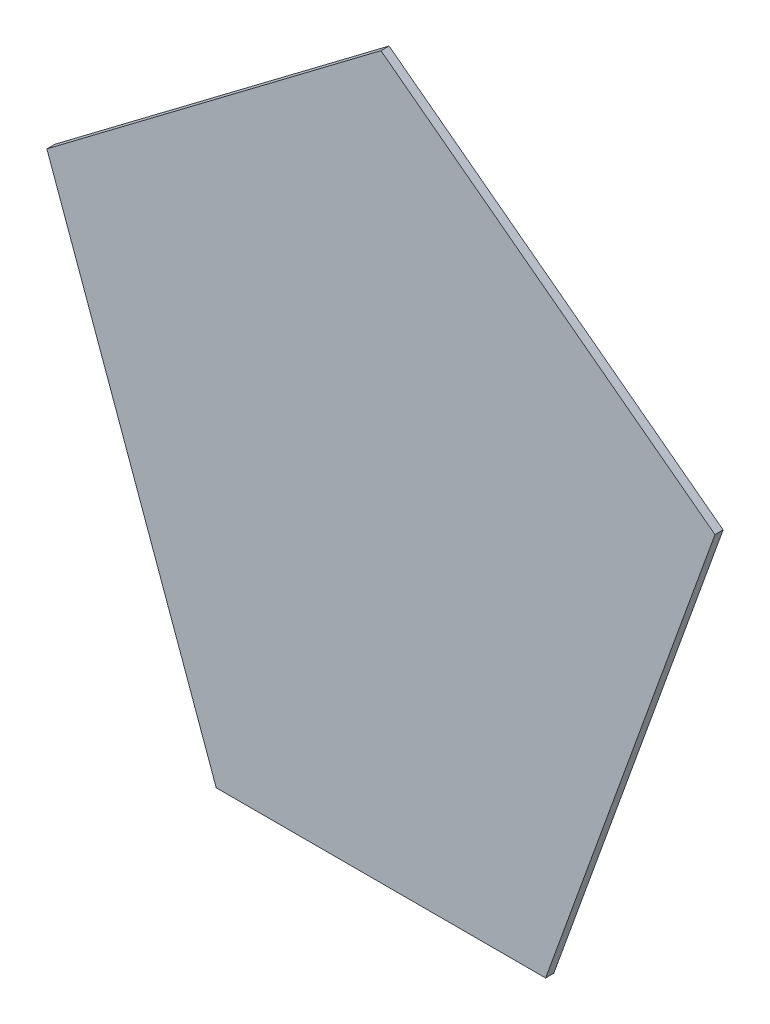
from build123d import *

# Parameters (mm, degrees)
BOSS_EXTRU_1_DEPTH = 3.5


with BuildPart() as part:
    # Esquisse1 → Boss.-Extru.1 (new body)
    with BuildSketch(Plane.XY):
        Polygon((-7.772495449, -270.02659005), (-151.459873294, -378.442167565), (-78.608554807, -580.02659005), (63.06356391, -580.02659005), (135.914882397, -378.442167565), align=None)
    extrude(amount=-BOSS_EXTRU_1_DEPTH)


solid = part.part
